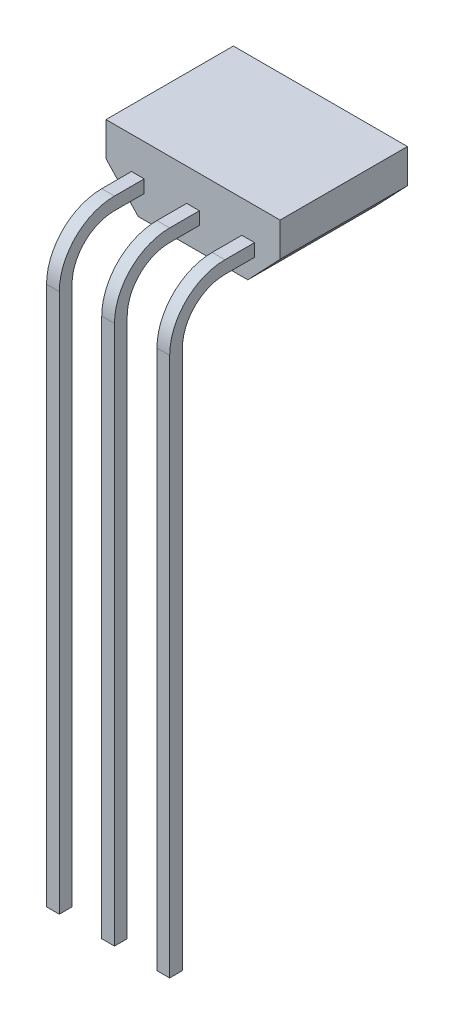
from build123d import *

# Parameters (mm, degrees)
SKETCH_1_W             = 4.1
SKETCH_1_H             = 3
EXTRUDE_1_DEPTH        = 1.6
CHAMFER_1_SIZE         = 0.76
CHAMFER_1_SIZE2        = 0.8
EXTRUDE_2_DEPTH        = 0.15
PATTERN_LINEAR_1_COUNT = 2
PATTERN_LINEAR_1_PITCH = 1.3
MIRROR_1_COPY_1_DEPTH  = 0.15
MIRROR_1_COPY_2_DEPTH  = 0.15


with BuildPart() as part:
    # Эскиз1 → Бобышка-Вытянуть1 (new body)
    with BuildSketch(Plane(origin=(0, 0, 0), x_dir=(1, 0, 0), z_dir=(0, 1, 0))):
        Rectangle(SKETCH_1_W, SKETCH_1_H)
    extrude(amount=EXTRUDE_1_DEPTH)

    # Фаска1
    chamfer_1_edges = [part.edges().sort_by_distance(p)[0] for p in [
        (2.05, 0, 0),
        (-2.05, 0, 0),
    ]]
    chamfer_1_side = [part.faces().sort_by_distance(p)[0] for p in [
        (0, 0, 0),
    ]]
    chamfer(chamfer_1_edges, length=CHAMFER_1_SIZE, length2=CHAMFER_1_SIZE2, reference=chamfer_1_side[0])

    # Эскиз2 → Бобышка-Вытянуть2 (add, symmetric)
    with BuildSketch(Plane(origin=(0, 0, 0), x_dir=(0, 0, -1), z_dir=(1, 0, 0))):
        with BuildLine():
            Line((-2.2, 0.84), (-1.5, 0.84))
            Line((-1.5, 0.84), (-1.5, 0.54))
            Line((-1.5, 0.54), (-2.2, 0.54))
            ThreePointArc((-2.2, 0.54), (-2.907106781, 0.247106781), (-3.2, -0.46))
            Line((-3.2, -0.46), (-3.2, -13.16))
            Line((-3.2, -13.16), (-3.5, -13.16))
            Line((-3.5, -13.16), (-3.5, -0.46))
            ThreePointArc((-3.5, -0.46), (-3.119238816, 0.459238816), (-2.2, 0.84))
        make_face()
    extrude_2 = extrude(amount=EXTRUDE_2_DEPTH, both=True)

    # Линейный массив1: Бобышка-Вытянуть2 ×2
    with Locations(*[(-i * PATTERN_LINEAR_1_PITCH, 0, 0) for i in range(1, PATTERN_LINEAR_1_COUNT)]):
        add(extrude_2)

    # Зеркальное отражение1 copy 1 sketch → Зеркальное отражение1 copy 1 (add, symmetric)
    with BuildSketch(Plane(origin=(1.3, 0, 0), x_dir=(0, 0, -1), z_dir=(-1, 0, 0))):
        with BuildLine():
            Line((-2.2, -0.84), (-1.5, -0.84))
            Line((-1.5, -0.84), (-1.5, -0.54))
            Line((-1.5, -0.54), (-2.2, -0.54))
            ThreePointArc((-2.2, -0.54), (-2.907106781, -0.247106781), (-3.2, 0.46))
            Line((-3.2, 0.46), (-3.2, 13.16))
            Line((-3.2, 13.16), (-3.5, 13.16))
            Line((-3.5, 13.16), (-3.5, 0.46))
            ThreePointArc((-3.5, 0.46), (-3.119238816, -0.459238816), (-2.2, -0.84))
        make_face()
    extrude(amount=MIRROR_1_COPY_1_DEPTH, both=True)

    # Зеркальное отражение1 copy 2 sketch → Зеркальное отражение1 copy 2 (add, symmetric)
    with BuildSketch(Plane(origin=(0, 0, 0), x_dir=(0, 0, -1), z_dir=(-1, 0, 0))):
        with BuildLine():
            Line((-2.2, -0.84), (-1.5, -0.84))
            Line((-1.5, -0.84), (-1.5, -0.54))
            Line((-1.5, -0.54), (-2.2, -0.54))
            ThreePointArc((-2.2, -0.54), (-2.907106781, -0.247106781), (-3.2, 0.46))
            Line((-3.2, 0.46), (-3.2, 13.16))
            Line((-3.2, 13.16), (-3.5, 13.16))
            Line((-3.5, 13.16), (-3.5, 0.46))
            ThreePointArc((-3.5, 0.46), (-3.119238816, -0.459238816), (-2.2, -0.84))
        make_face()
    extrude(amount=MIRROR_1_COPY_2_DEPTH, both=True)


solid = part.part
